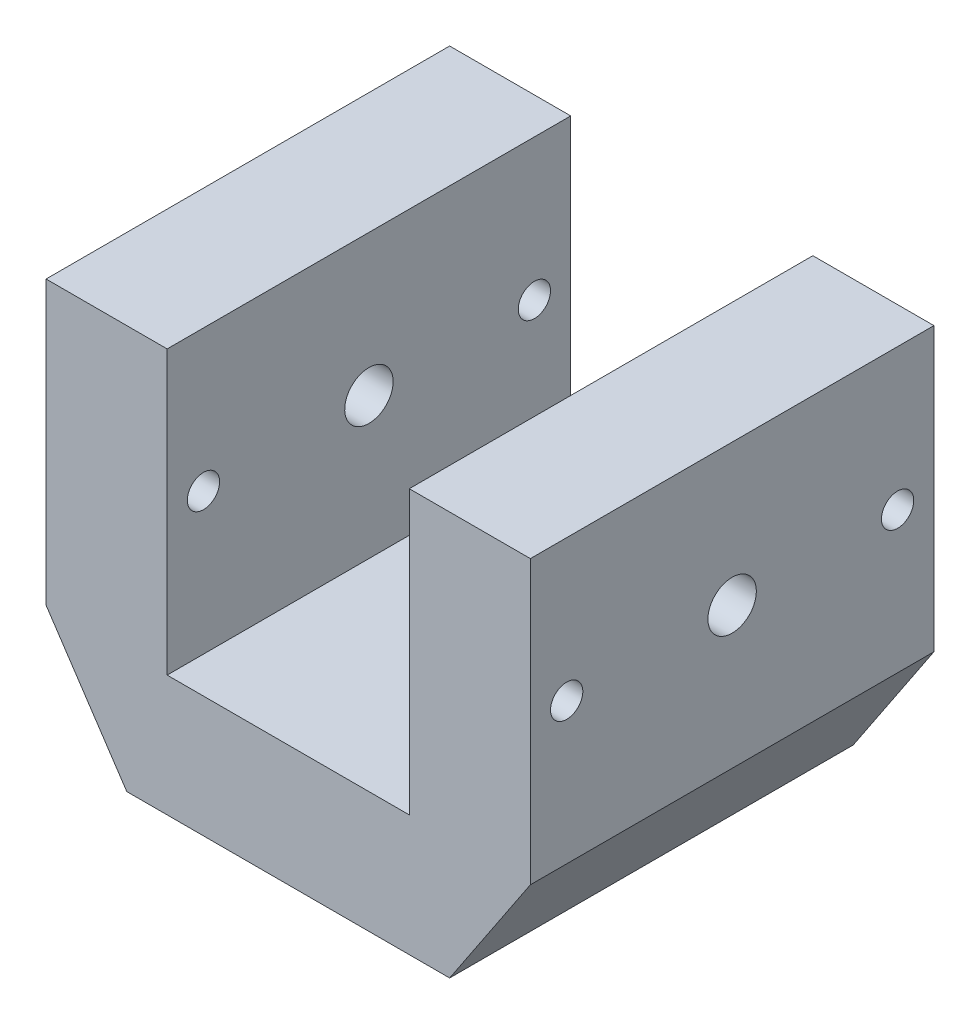
from build123d import *

# Parameters (mm, degrees)
SKETCH1_W               = 120
SKETCH1_H               = 100
BOSS_EXTRUDE1_DEPTH     = 100
SKETCH2_W               = 60
SKETCH2_H               = 70
CUT_EXTRUDE2_DEPTH      = 101
CUT_EXTRUDE2_DEPTH_BACK = 1
SKETCH3_R               = 6
CUT_EXTRUDE3_DEPTH      = 51
CUT_EXTRUDE3_DEPTH_BACK = 51
SKETCH5_R               = 4
CUT_EXTRUDE4_DEPTH      = 61
CUT_EXTRUDE4_DEPTH_BACK = 61
SKETCH6_R               = 6
CUT_EXTRUDE5_DEPTH      = 61
CUT_EXTRUDE5_DEPTH_BACK = 61
CUT_EXTRUDE7_START      = -20
SKETCH7_R               = 11
CUT_EXTRUDE7_DEPTH      = 13


with BuildPart() as part:
    # Sketch1 → Boss-Extrude1 (new body)
    with BuildSketch(Plane.XY):
        Rectangle(SKETCH1_W, SKETCH1_H)
    extrude(amount=BOSS_EXTRUDE1_DEPTH)

    # Sketch2 → Cut-Extrude2 (cut, two sides)
    with BuildSketch(Plane.XY) as cut_extrude2_sk:
        Polygon((-60, -20), (-40, -50), (-60, -50), align=None)
        with Locations((0, 15)):
            Rectangle(SKETCH2_W, SKETCH2_H)
        Polygon((60, -50), (40, -50), (60, -20), align=None)
    extrude(amount=CUT_EXTRUDE2_DEPTH, mode=Mode.SUBTRACT)
    extrude(cut_extrude2_sk.sketch, amount=-CUT_EXTRUDE2_DEPTH_BACK, mode=Mode.SUBTRACT)

    # Sketch3 → Cut-Extrude3 (cut, two sides)
    with BuildSketch(Plane(origin=(0, 0, 0), x_dir=(1, 0, 0), z_dir=(0, 1, 0))) as cut_extrude3_sk:
        with Locations((0, -50)):
            Circle(SKETCH3_R)
    extrude(amount=CUT_EXTRUDE3_DEPTH, mode=Mode.SUBTRACT)
    extrude(cut_extrude3_sk.sketch, amount=-CUT_EXTRUDE3_DEPTH_BACK, mode=Mode.SUBTRACT)

    # Sketch5 → Cut-Extrude4 (cut, two sides)
    with BuildSketch(Plane(origin=(0, 0, 0), x_dir=(0, 0, -1), z_dir=(1, 0, 0))) as cut_extrude4_sk:
        with Locations((-91, 15)):
            Circle(SKETCH5_R)
        with Locations((-9, 15)):
            Circle(SKETCH5_R)
    extrude(amount=CUT_EXTRUDE4_DEPTH, mode=Mode.SUBTRACT)
    extrude(cut_extrude4_sk.sketch, amount=-CUT_EXTRUDE4_DEPTH_BACK, mode=Mode.SUBTRACT)

    # Sketch6 → Cut-Extrude5 (cut, two sides)
    with BuildSketch(Plane(origin=(0, 0, 0), x_dir=(0, 0, -1), z_dir=(1, 0, 0))) as cut_extrude5_sk:
        with Locations((-50, 15)):
            Circle(SKETCH6_R)
    extrude(amount=CUT_EXTRUDE5_DEPTH, mode=Mode.SUBTRACT)
    extrude(cut_extrude5_sk.sketch, amount=-CUT_EXTRUDE5_DEPTH_BACK, mode=Mode.SUBTRACT)

    # Sketch7 → Cut-Extrude7 (cut)
    with BuildSketch(Plane(origin=(0, 0, 0), x_dir=(1, 0, 0), z_dir=(0, 1, 0)).offset(CUT_EXTRUDE7_START)):
        with Locations((0, -50)):
            Circle(SKETCH7_R)
    extrude(amount=-CUT_EXTRUDE7_DEPTH, mode=Mode.SUBTRACT)


solid = part.part
